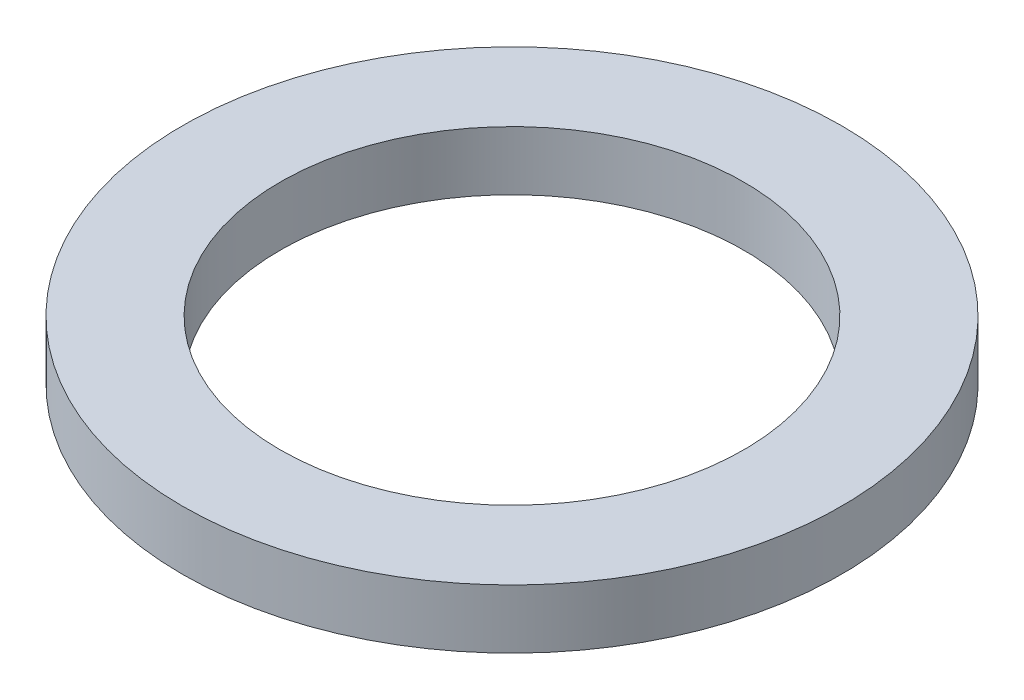
from build123d import *

# Parameters (mm, degrees)
SKETCH1_R           = 11.1633
SKETCH1_R_2         = 7.85495
BOSS_EXTRUDE1_DEPTH = 2


with BuildPart() as part:
    # Sketch1 → Boss-Extrude1 (new body)
    with BuildSketch(Plane(origin=(0, 0, 0), x_dir=(1, 0, 0), z_dir=(0, 1, 0))):
        Circle(SKETCH1_R)
        Circle(SKETCH1_R_2, mode=Mode.SUBTRACT)
    extrude(amount=BOSS_EXTRUDE1_DEPTH)


solid = part.part
